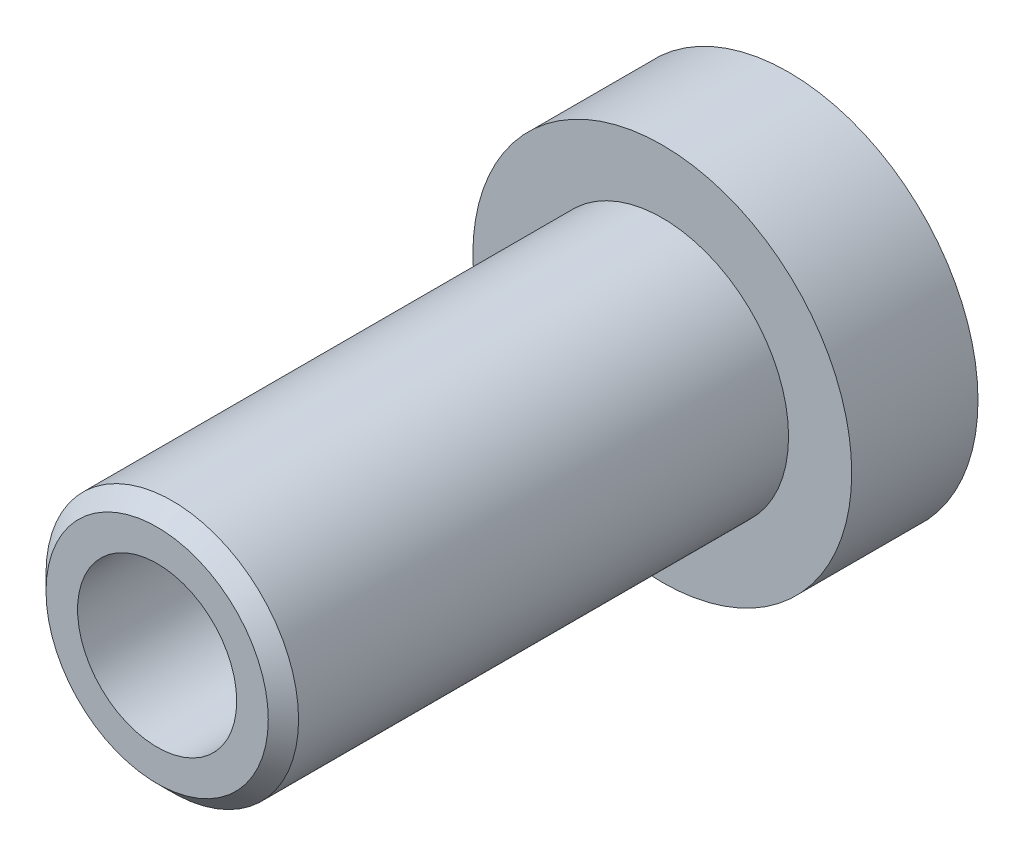
from build123d import *

# Parameters (mm, degrees)
SKETCH2_R          = 31.5
CUT_EXTRUDE1_DEPTH = 251


with BuildPart() as part:
    # Sketch1 → Revolve1 (revolve)
    with BuildSketch(Plane(origin=(0, 0, 0), x_dir=(1, 0, 0), z_dir=(0, 1, 0))):
        Polygon((0, 73.759969248), (75, 73.759969248), (75, 23.759969248), (50, 23.759969248), (50, -170.240030752), (44, -176.240030752), (0, -176.240030752), align=None)
    revolve(axis=Axis((0, 0, -73.759969248), (0, 0, 1)))

    # Sketch2 → Cut-Extrude1 (cut, through all)
    with BuildSketch(Plane.XY.offset(176.240030752)):
        Circle(SKETCH2_R)
    extrude(amount=-CUT_EXTRUDE1_DEPTH, mode=Mode.SUBTRACT)


solid = part.part
